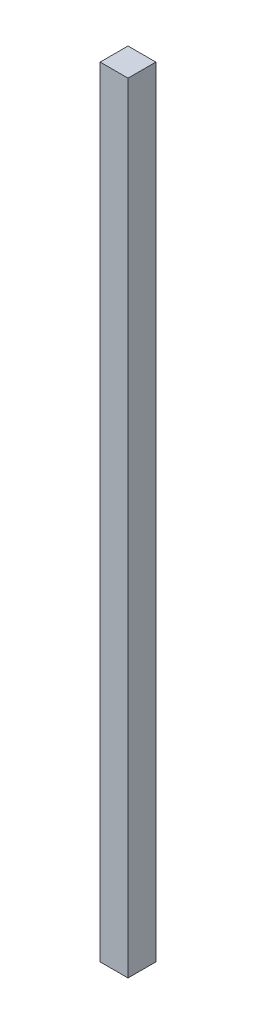
from build123d import *

# Parameters (mm, degrees)
SKETCH1_W           = 15
SKETCH1_H           = 15
BOSS_EXTRUDE1_DEPTH = 420


with BuildPart() as part:
    # Sketch1 → Boss-Extrude1 (new body)
    with BuildSketch(Plane(origin=(0, 0, 0), x_dir=(1, 0, 0), z_dir=(0, 1, 0))):
        Rectangle(SKETCH1_W, SKETCH1_H)
    extrude(amount=BOSS_EXTRUDE1_DEPTH)


solid = part.part
